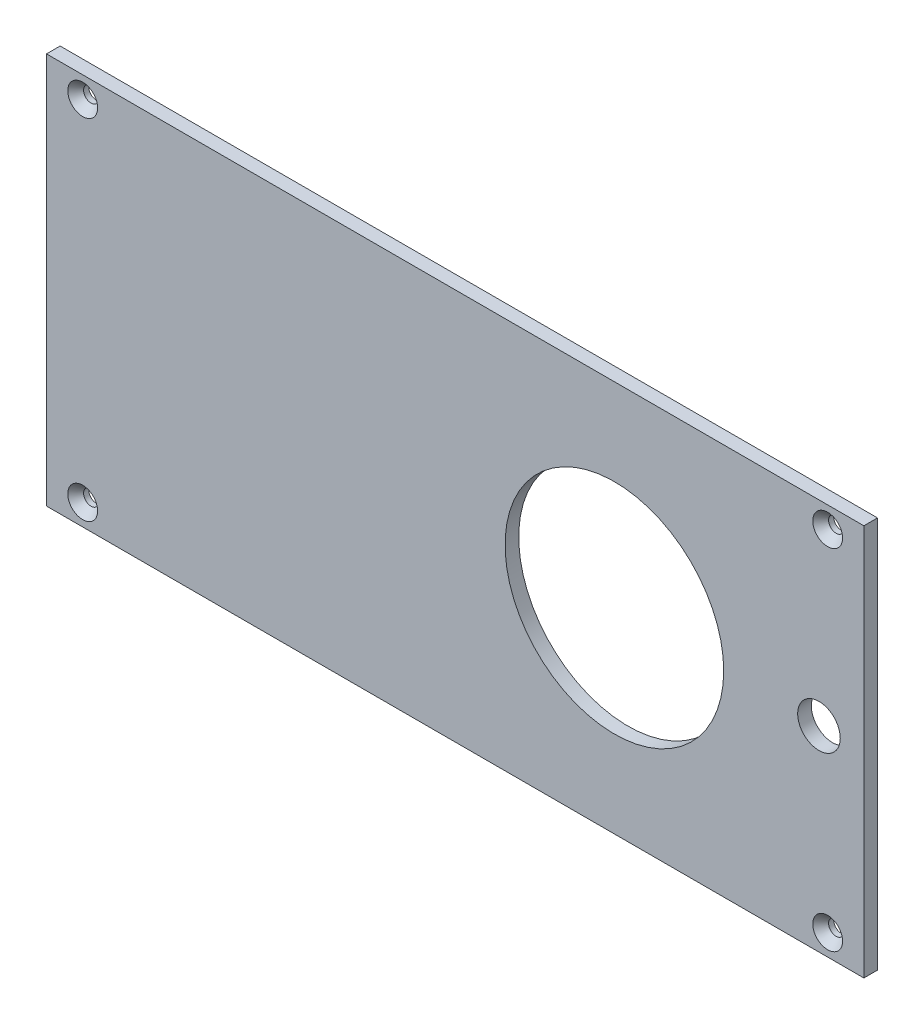
from build123d import *

# Parameters (mm, degrees)
SKETCH1_W                                     = 96
SKETCH1_H                                     = 46
BOSS_EXTRUDE1_DEPTH                           = 1.6002
SKETCH2_R                                     = 12.8397
CUT_EXTRUDE1_DEPTH                            = 2.6002
CSK_FOR_0_FLAT_HEAD_SOCKET_CAP_SCREW1_A_COUNT = 2
CSK_FOR_0_FLAT_HEAD_SOCKET_CAP_SCREW1_A_PITCH = 41
CSK_FOR_0_FLAT_HEAD_SOCKET_CAP_SCRE_2_COUNT   = 2
CSK_FOR_0_FLAT_HEAD_SOCKET_CAP_SCRE_2_PITCH   = 96.629446858
CSK_FOR_0_FLAT_HEAD_SOCKET_CAP_SCRE_3_COUNT   = 2
CSK_FOR_0_FLAT_HEAD_SOCKET_CAP_SCRE_3_PITCH   = 87.5
SKETCH14_R                                    = 2.5
CUT_EXTRUDE2_DEPTH                            = 10


with BuildPart() as part:
    # Sketch1 → Boss-Extrude1 (new body)
    with BuildSketch(Plane.XY):
        with Locations((48, 23)):
            Rectangle(SKETCH1_W, SKETCH1_H)
    extrude(amount=BOSS_EXTRUDE1_DEPTH)

    # Sketch2 → Cut-Extrude1 (cut, through all)
    with BuildSketch(Plane.XY.offset(1.6002)):
        with Locations((66.7, 23)):
            Circle(SKETCH2_R)
    extrude(amount=-CUT_EXTRUDE1_DEPTH, mode=Mode.SUBTRACT)

    # Sketch7 → CSK for #0 Flat Head Socket Cap Screw1 (revolve, cut)
    with BuildSketch(Plane(origin=(4.25, 43.5, 1.6002), x_dir=(0, -1, 0), z_dir=(1, 0, 0))):
        Polygon((0, 0), (0, 1.6002), (0.889, 1.6002), (0.889, 0.993458156), (1.7526, 0), align=None)
    csk_for_0_flat_head_socket_cap_screw1 = revolve(axis=Axis((4.25, 43.5, 7.9502), (0, 0, -1)), mode=Mode.SUBTRACT)

    # CSK for #0 Flat Head Socket Cap Screw1 a: CSK for #0 Flat Head Socket Cap Screw1 ×2
    with Locations(*[(0, -i * CSK_FOR_0_FLAT_HEAD_SOCKET_CAP_SCREW1_A_PITCH, 0) for i in range(1, CSK_FOR_0_FLAT_HEAD_SOCKET_CAP_SCREW1_A_COUNT)]):
        add(csk_for_0_flat_head_socket_cap_screw1, mode=Mode.SUBTRACT)

    # CSK for _0 Flat Head Socket Cap Scre 2: CSK for #0 Flat Head Socket Cap Screw1 ×2
    with Locations(*[Vector(0.905521069, -0.424301301, 0) * (i * CSK_FOR_0_FLAT_HEAD_SOCKET_CAP_SCRE_2_PITCH) for i in range(1, CSK_FOR_0_FLAT_HEAD_SOCKET_CAP_SCRE_2_COUNT)]):
        add(csk_for_0_flat_head_socket_cap_screw1, mode=Mode.SUBTRACT)

    # CSK for _0 Flat Head Socket Cap Scre 3: CSK for #0 Flat Head Socket Cap Screw1 ×2
    with Locations(*[(i * CSK_FOR_0_FLAT_HEAD_SOCKET_CAP_SCRE_3_PITCH, 0, 0) for i in range(1, CSK_FOR_0_FLAT_HEAD_SOCKET_CAP_SCRE_3_COUNT)]):
        add(csk_for_0_flat_head_socket_cap_screw1, mode=Mode.SUBTRACT)

    # Sketch14 → Cut-Extrude2 (cut)
    with BuildSketch(Plane.XY.offset(1.6002)):
        with Locations((90.727040544, 23)):
            Circle(SKETCH14_R)
    extrude(amount=-CUT_EXTRUDE2_DEPTH, mode=Mode.SUBTRACT)


solid = part.part
